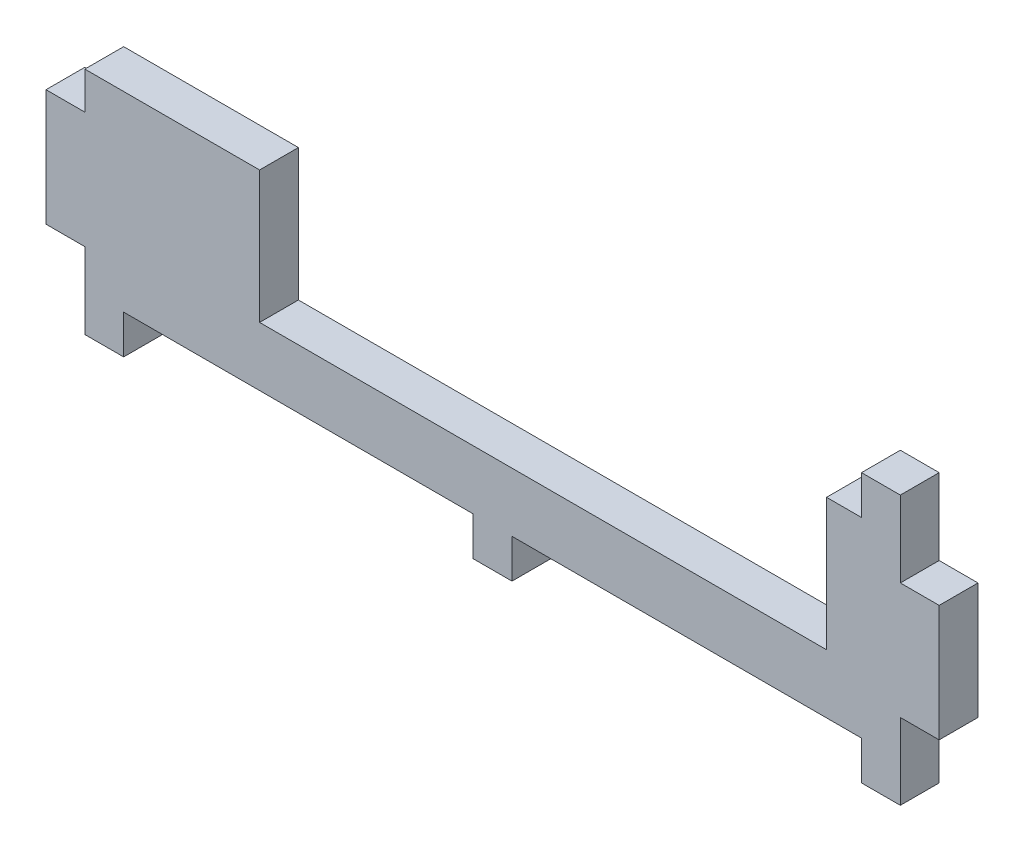
from build123d import *

# Parameters (mm, degrees)
SKETCH1_W           = 105
SKETCH1_H           = 12.3
BOSS_EXTRUDE1_DEPTH = 5
SKETCH2_W           = 5
SKETCH2_H           = 5
BOSS_EXTRUDE2_DEPTH = 5
SKETCH3_W           = 73
SKETCH3_H           = 5
CUT_EXTRUDE1_DEPTH  = 17
SKETCH4_W           = 5
SKETCH4_H           = 5
BOSS_EXTRUDE3_DEPTH = 5
SKETCH5_W           = 5
SKETCH5_H           = 15
BOSS_EXTRUDE4_DEPTH = 5


with BuildPart() as part:
    # Sketch1 → Boss-Extrude1 (new body)
    with BuildSketch(Plane.XY):
        Rectangle(SKETCH1_W, SKETCH1_H)
    extrude(amount=BOSS_EXTRUDE1_DEPTH)

    # Sketch2 → Boss-Extrude2 (add)
    with BuildSketch(Plane.XZ.offset(6.15)):
        with Locations((50, 2.5)):
            Rectangle(SKETCH2_W, SKETCH2_H)
    extrude(amount=BOSS_EXTRUDE2_DEPTH)

    # Mirror1: part across plane


with BuildPart() as part_1:
    add(part.part)
    add(part.part.mirror(Plane(origin=(-52.5, 6.15, 5), x_dir=(0, 0, 1), z_dir=(0, -1, 0))))

    # Sketch3 → Cut-Extrude1 (cut)
    with BuildSketch(Plane(origin=(0, 18.45, 0), x_dir=(1, 0, 0), z_dir=(0, 1, 0))):
        with Locations((6.5, -2.5)):
            Rectangle(SKETCH3_W, SKETCH3_H)
    extrude(amount=-CUT_EXTRUDE1_DEPTH, mode=Mode.SUBTRACT)

    # Sketch4 → Boss-Extrude3 (add)
    with BuildSketch(Plane.XZ.offset(6.15)):
        with Locations((0, 2.5)):
            Rectangle(SKETCH4_W, SKETCH4_H)
        with Locations((-50, 2.5)):
            Rectangle(SKETCH4_W, SKETCH4_H)
    extrude(amount=BOSS_EXTRUDE3_DEPTH)

    # Sketch5 → Boss-Extrude4 (add)
    with BuildSketch(Plane.ZY.offset(52.5)):
        with Locations((2.5, 6.15)):
            Rectangle(SKETCH5_W, SKETCH5_H)
    boss_extrude4 = extrude(amount=BOSS_EXTRUDE4_DEPTH)

    # Mirror2: Boss-Extrude4 across plane
    add(boss_extrude4.mirror(Plane(origin=(0, 0, 0), x_dir=(0, 0, 1), z_dir=(1, 0, 0))))


solid = part_1.part
